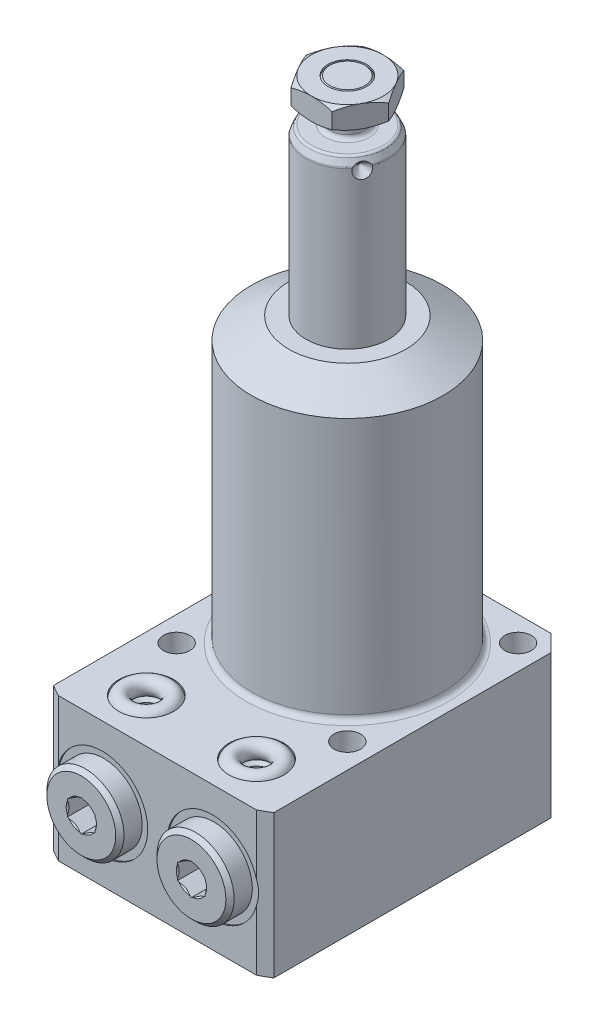
from build123d import *

# Parameters (mm, degrees)
FILLET2_R           = 0.75
FILLET3_R           = 0.5
SKETCH3_R           = 3.5
EXTRUDE3_DEPTH      = 4
CIRPATTERN1_COUNT   = 3
SKETCH7_OUTSIDE_W   = 111.656
SKETCH7_OUTSIDE_H   = 111.656
SKETCH7_OUTSIDE_W_2 = 40
SKETCH7_OUTSIDE_H_2 = 54.5
CUT_EXTRUDE5_DEPTH  = 27
SKETCH8_R           = 2.4
CUT_EXTRUDE6_DEPTH  = 116.25
CIRPATTERN2_COUNT   = 4
CHAMFER1_SIZE       = 3
FILLET5_R           = 1
CUT_EXTRUDE8_DEPTH  = 4.06
SKETCH16_R          = 1.5


with BuildPart() as part:
    # Sketch1 → Revolve2 (revolve)
    with BuildSketch(Plane.XY, mode=Mode.PRIVATE) as revolve2_sk:
        Polygon((7.5, 0), (7.5, 80), (6.800538513, 81.5), (3.25, 81.5), (3.25, 83.5), (3.935, 84.185), (3.935, 88.5), (3.185, 89.25), (0, 89.25), (0, 0), align=None)
    revolve(revolve2_sk.sketch.rotate(Axis((0, -3.075, 0), (0, 1, 0)), 90), axis=Axis((0, -3.075, 0), (0, 1, 0)))  # turned: the seam where the file's is

    # Fillet2
    fillet2_edges = [part.edges().sort_by_distance(p)[0] for p in [
        (0, 81.5, 3.25),
        (0, 83.5, 3.25),
    ]]
    fillet(fillet2_edges, radius=FILLET2_R)

    # Fillet3
    fillet3_edges = [part.edges().sort_by_distance(p)[0] for p in [
        (0, 80, 7.5),
        (0, 81.5, 6.800538513),
    ]]
    fillet(fillet3_edges, radius=FILLET3_R)

    # Sketch2 → Cut-Revolve1 (revolve, cut)
    with BuildSketch(Plane(origin=(0, 0, 0), x_dir=(0, 0, -1), z_dir=(1, 0, 0)), mode=Mode.PRIVATE) as cut_revolve1_sk:
        Polygon((6, 79.5), (7.5, 78), (7.5, 79.5), align=None)
    cut_revolve1 = revolve(cut_revolve1_sk.sketch.rotate(Axis((0, 79.5, -4.20155099), (0, 0, -1)), 90), axis=Axis((0, 79.5, -4.20155099), (0, 0, -1)), mode=Mode.SUBTRACT)  # turned: the seam where the file's is

    # Sketch3 → Extrude3 (add)
    with BuildSketch(Plane(origin=(0, 89.25, 0), x_dir=(1, 0, 0), z_dir=(0, 1, 0))):
        Polygon((7.505553499, 0), (3.75277675, 6.5), (-3.75277675, 6.5), (-7.505553499, 0), (-3.75277675, -6.5), (3.75277675, -6.5), align=None)
        with Locations(Location((0, 0, 0), (0, 0, 270))):  # turned: the seam where the file's is
            Circle(SKETCH3_R, mode=Mode.SUBTRACT)
    extrude(amount=-EXTRUDE3_DEPTH)

    # CirPattern1: Cut-Revolve1 ×3 about axis
    cirpattern1_axis = Axis((0, -3.075, 0), (0, -1, 0))
    for i in range(1, CIRPATTERN1_COUNT):
        add(cut_revolve1.rotate(cirpattern1_axis, i * 360 / CIRPATTERN1_COUNT), mode=Mode.SUBTRACT)

    # Sketch4 → Cut-Revolve3 (revolve, cut)
    with BuildSketch(Plane(origin=(0, 0, 0), x_dir=(0, 0, -1), z_dir=(1, 0, 0))):
        Polygon((6.5, 89.25), (9.5, 89.25), (9.5, 87.517949192), align=None)
        Polygon((9.5, 86.982050808), (6.5, 85.25), (9.5, 85.25), align=None)
    revolve(axis=Axis((0, -3.075, 0), (0, -1, 0)), mode=Mode.SUBTRACT)

    # Sketch6 → Revolve3 (revolve)
    with BuildSketch(Plane.XY, mode=Mode.PRIVATE) as revolve3_sk:
        Polygon((0, 51.5), (10.625, 51.5), (17.385, 47.59711218), (17.385, 0), (38.895, 0), (38.895, -26), (0, -26), align=None)
    revolve(revolve3_sk.sketch.rotate(Axis((0, -26, 0), (0, 1, 0)), 90), axis=Axis((0, -26, 0), (0, 1, 0)))  # turned: the seam where the file's is

    # Sketch7 outside → Cut-Extrude5 (cut, through all)
    with BuildSketch(Plane(origin=(0, 0, 0), x_dir=(-1, 0, 0), z_dir=(0, 1, 0))):
        Rectangle(SKETCH7_OUTSIDE_W, SKETCH7_OUTSIDE_H)
        with Locations((0, 7.25)):
            Rectangle(SKETCH7_OUTSIDE_W_2, SKETCH7_OUTSIDE_H_2, mode=Mode.SUBTRACT)
    extrude(amount=-CUT_EXTRUDE5_DEPTH, mode=Mode.SUBTRACT)

    # Sketch8 → Cut-Extrude6 (cut, through all)
    with BuildSketch(Plane.XZ.offset(26)):
        with Locations(Location((-15.5, 15.5, 0), (0, 0, 270))):  # turned: the seam where the file's is
            Circle(SKETCH8_R)
    cut_extrude6 = extrude(amount=-CUT_EXTRUDE6_DEPTH, mode=Mode.SUBTRACT)

    # CirPattern2: Cut-Extrude6 ×4 about axis
    cirpattern2_axis = Axis((0, 0, 0), (0, 1, 0))
    for i in range(1, CIRPATTERN2_COUNT):
        add(cut_extrude6.rotate(cirpattern2_axis, i * 360 / CIRPATTERN2_COUNT), mode=Mode.SUBTRACT)

    # Chamfer1
    chamfer1_edges = [part.edges().sort_by_distance(p)[0] for p in [
        (-20, -13, -20),
        (20, -13, -20),
    ]]
    chamfer(chamfer1_edges, length=CHAMFER1_SIZE)

    # Fillet5
    fillet5_edges = [part.edges().sort_by_distance(p)[0] for p in [
        (0, 0, 17.385),
    ]]
    fillet(fillet5_edges, radius=FILLET5_R)

    # Sketch11 → Cut-Revolve5 (revolve, cut)
    with BuildSketch(Plane.XZ.offset(13), mode=Mode.PRIVATE) as cut_revolve5_sk:
        Polygon((-18.25, 34.5), (-18.25, 34.25), (-15, 34.25), (-14.42, 33.67), (-14.42, 19.09), (-10, 19.09), (-10, 34.5), align=None)
    cut_revolve5 = revolve(cut_revolve5_sk.sketch.rotate(Axis((-10, -13, 42.971570338), (0, 0, -1)), 180), axis=Axis((-10, -13, 42.971570338), (0, 0, -1)), mode=Mode.SUBTRACT)  # turned: the seam where the file's is

    # Sketch13 → Cut-Revolve6 (revolve, cut)
    with BuildSketch(Plane.XY.offset(26.5)):
        Polygon((-12.5, -14), (-12.5, -23.125), (-13.125, -23.75), (-15, -23.75), (-15, -26), (-10, -26), (-10, -14), align=None)
    cut_revolve6 = revolve(axis=Axis((-10, 15.209907045, 26.5), (0, -1, 0)), mode=Mode.SUBTRACT)

    # Sketch14 → Revolve6 (revolve)
    with BuildSketch(Plane.XZ.offset(13)):
        Polygon((-12.75, 38.31), (-16.25, 38.31), (-17, 37.56), (-17, 34.25), (-14.125, 34.25), (-14.125, 31.80784845), (-10, 31.80784845), (-10, 31.80884845), (-12.5, 33.310999998), (-12.5, 38.06), align=None)
    revolve6 = revolve(axis=Axis((-10, -13, 32.588064048), (0, 0, 1)))

    # Mirror4: Cut-Revolve6 across plane
    add(cut_revolve6.mirror(Plane(origin=(0, -13, 0), x_dir=(0, 0, 1), z_dir=(0, -1, 0))), mode=Mode.SUBTRACT)

    # Sketch15 → Cut-Extrude8 (cut)
    with BuildSketch(Plane.XY.offset(38.31)):
        Polygon((-7.5, -14.443375673), (-7.5, -11.556624327), (-10, -10.113248654), (-12.5, -11.556624327), (-12.5, -14.443375673), (-10, -15.886751346), align=None)
    cut_extrude8 = extrude(amount=-CUT_EXTRUDE8_DEPTH, mode=Mode.SUBTRACT)

    # Mirror1: Cut-Revolve5, Cut-Revolve6, Revolve6, Cut-Extrude8 across plane
    add(cut_revolve5.mirror(Plane(origin=(0, 0, 0), x_dir=(0, 0, 1), z_dir=(1, 0, 0))), mode=Mode.SUBTRACT)
    add(cut_revolve6.mirror(Plane(origin=(0, 0, 0), x_dir=(0, 0, 1), z_dir=(1, 0, 0))), mode=Mode.SUBTRACT)
    add(revolve6.mirror(Plane(origin=(0, 0, 0), x_dir=(0, 0, 1), z_dir=(1, 0, 0))))
    add(cut_extrude8.mirror(Plane(origin=(0, 0, 0), x_dir=(0, 0, 1), z_dir=(1, 0, 0))), mode=Mode.SUBTRACT)

    # Mirror1 copy 1 sketch → Mirror1 copy 1 (revolve, cut)
    with BuildSketch(Plane(origin=(0, -26, 26.5), x_dir=(-1, 0, 0), z_dir=(0, 0, 1))):
        Polygon((-12.5, -14), (-12.5, -23.125), (-13.125, -23.75), (-15, -23.75), (-15, -26), (-10, -26), (-10, -14), align=None)
    revolve(axis=Axis((10, -41.209907045, 26.5), (0, 1, 0)), mode=Mode.SUBTRACT)


with BuildPart() as body_2:
    # Sketch16 → Revolve7 (revolve)
    with BuildSketch(Plane.XY.offset(26.5)):
        with Locations((-13.5, -25.25)):
            Circle(SKETCH16_R)
    revolve(axis=Axis((-10, 9.321927472, 26.5), (0, -1, 0)))


with BuildPart() as body_3:
    # Mirror3: mirrored copy
    add(body_2.part.mirror(Plane(origin=(0, 0, 0), x_dir=(0, 0, 1), z_dir=(1, 0, 0))))


with BuildPart() as body_4:
    # Mirror5: mirrored copy
    add(body_2.part.mirror(Plane(origin=(0, -13, 0), x_dir=(0, 0, 1), z_dir=(0, -1, 0))))


with BuildPart() as body_5:
    # Mirror5 2: mirrored copy
    add(body_3.part.mirror(Plane(origin=(0, -13, 0), x_dir=(0, 0, 1), z_dir=(0, -1, 0))))


solid = Compound([part.part, body_2.part, body_3.part, body_4.part, body_5.part])
